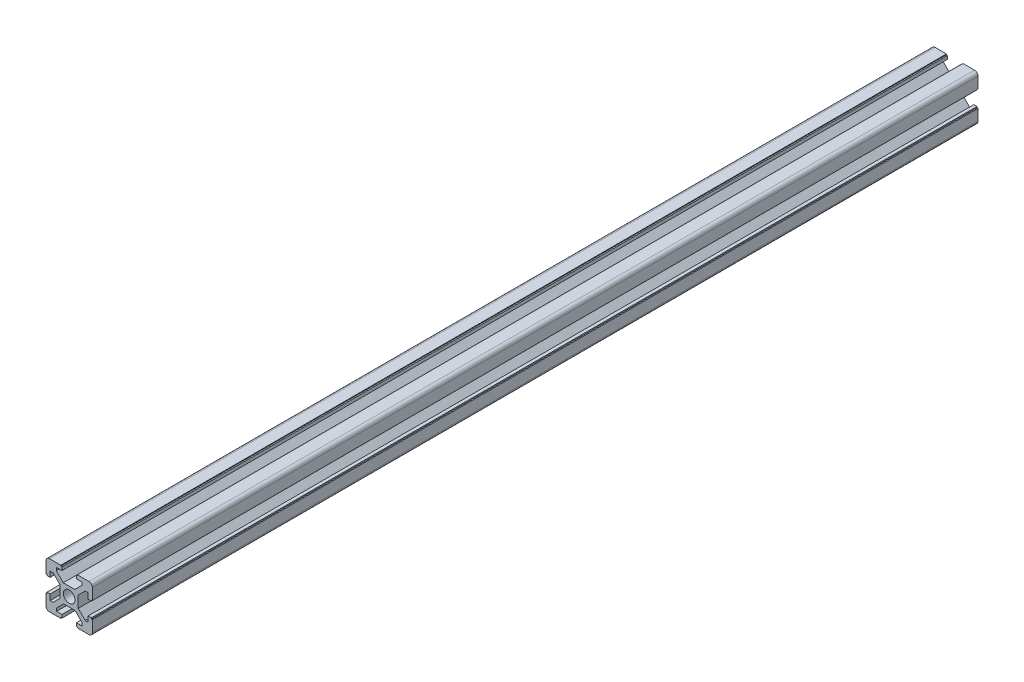
from build123d import *

# Parameters (mm, degrees)
SKETCH1_R           = 2.5
BOSS_EXTRUDE1_DEPTH = 382


with BuildPart() as part:
    # Sketch1 → Boss-Extrude1 (new body)
    with BuildSketch(Plane.XY):
        with BuildLine():
            Line((14.316619525, 10.387216168), (13.029112559, 10.387216168))
            Line((13.029112559, 10.387216168), (13.029112559, 12.855371932))
            Line((13.029112559, 12.855371932), (11.656738465, 12.855371932))
            Line((11.656738465, 12.855371932), (11.656738465, 12.336659272))
            Line((11.656738465, 12.336659272), (11.229112559, 12.336659272))
            Line((11.229112559, 12.336659272), (11.229112559, 7.521203168))
            ThreePointArc((11.229112559, 7.521203168), (11.668452387, 6.460542996), (12.729112559, 6.021203168))
            Line((12.729112559, 6.021203168), (17.624436699, 6.021203168))
            Line((17.624436699, 6.021203168), (17.624436699, 6.382997838))
            Line((17.624436699, 6.382997838), (18.129112559, 6.382997838))
            Line((18.129112559, 6.382997838), (18.129112559, 7.755371932))
            Line((18.129112559, 7.755371932), (15.794230869, 7.755371932))
            Line((15.794230869, 7.755371932), (15.794230869, 9.042878898))
            Line((15.794230869, 9.042878898), (18.806723903, 12.055371932))
            Line((18.806723903, 12.055371932), (23.784775289, 12.055371932))
            Line((23.784775289, 12.055371932), (26.797268323, 9.042878898))
            Line((26.797268323, 9.042878898), (26.797268323, 7.755371932))
            Line((26.797268323, 7.755371932), (24.329112559, 7.755371932))
            Line((24.329112559, 7.755371932), (24.329112559, 6.382997838))
            Line((24.329112559, 6.382997838), (24.847825219, 6.382997838))
            Line((24.847825219, 6.382997838), (24.847825219, 6.021203168))
            Line((24.847825219, 6.021203168), (29.729112559, 6.021203168))
            ThreePointArc((29.729112559, 6.021203168), (30.789772731, 6.460542996), (31.229112559, 7.521203168))
            Line((31.229112559, 7.521203168), (31.229112559, 12.350696072))
            Line((31.229112559, 12.350696072), (30.801486653, 12.350696072))
            Line((30.801486653, 12.350696072), (30.801486653, 12.855371932))
            Line((30.801486653, 12.855371932), (29.429112559, 12.855371932))
            Line((29.429112559, 12.855371932), (29.429112559, 10.520490242))
            Line((29.429112559, 10.520490242), (28.141605593, 10.520490242))
            Line((28.141605593, 10.520490242), (25.129112559, 13.532983276))
            Line((25.129112559, 13.532983276), (25.129112559, 18.511034662))
            Line((25.129112559, 18.511034662), (28.141605593, 21.523527696))
            Line((28.141605593, 21.523527696), (29.429112559, 21.523527696))
            Line((29.429112559, 21.523527696), (29.429112559, 19.055371932))
            Line((29.429112559, 19.055371932), (30.801486653, 19.055371932))
            Line((30.801486653, 19.055371932), (30.801486653, 19.574084592))
            Line((30.801486653, 19.574084592), (31.229112559, 19.574084592))
            Line((31.229112559, 19.574084592), (31.229112559, 24.389540696))
            ThreePointArc((31.229112559, 24.389540696), (30.789772731, 25.450200868), (29.729112559, 25.889540696))
            Line((29.729112559, 25.889540696), (24.833788419, 25.889540696))
            Line((24.833788419, 25.889540696), (24.833788419, 25.527746026))
            Line((24.833788419, 25.527746026), (24.329112559, 25.527746026))
            Line((24.329112559, 25.527746026), (24.329112559, 24.155371932))
            Line((24.329112559, 24.155371932), (26.663994249, 24.155371932))
            Line((26.663994249, 24.155371932), (26.663994249, 22.867864966))
            Line((26.663994249, 22.867864966), (23.651501215, 19.855371932))
            Line((23.651501215, 19.855371932), (18.673449829, 19.855371932))
            Line((18.673449829, 19.855371932), (15.660956795, 22.867864966))
            Line((15.660956795, 22.867864966), (15.660956795, 24.155371932))
            Line((15.660956795, 24.155371932), (18.129112559, 24.155371932))
            Line((18.129112559, 24.155371932), (18.129112559, 25.527746026))
            Line((18.129112559, 25.527746026), (17.610399899, 25.527746026))
            Line((17.610399899, 25.527746026), (17.610399899, 25.889540696))
            Line((17.610399899, 25.889540696), (12.729112559, 25.889540696))
            ThreePointArc((12.729112559, 25.889540696), (11.668452387, 25.450200868), (11.229112559, 24.389540696))
            Line((11.229112559, 24.389540696), (11.229112559, 19.560047792))
            Line((11.229112559, 19.560047792), (11.656738465, 19.560047792))
            Line((11.656738465, 19.560047792), (11.656738465, 19.055371932))
            Line((11.656738465, 19.055371932), (13.029112559, 19.055371932))
            Line((13.029112559, 19.055371932), (13.029112559, 21.390253622))
            Line((13.029112559, 21.390253622), (14.316619525, 21.390253622))
            Line((14.316619525, 21.390253622), (17.329112559, 18.377760588))
            Line((17.329112559, 18.377760588), (17.329112559, 13.399709202))
            Line((17.329112559, 13.399709202), (14.316619525, 10.387216168))
        make_face()
        with Locations((21.229112559, 15.955371932)):
            Circle(SKETCH1_R, mode=Mode.SUBTRACT)
    extrude(amount=BOSS_EXTRUDE1_DEPTH)


solid = part.part
